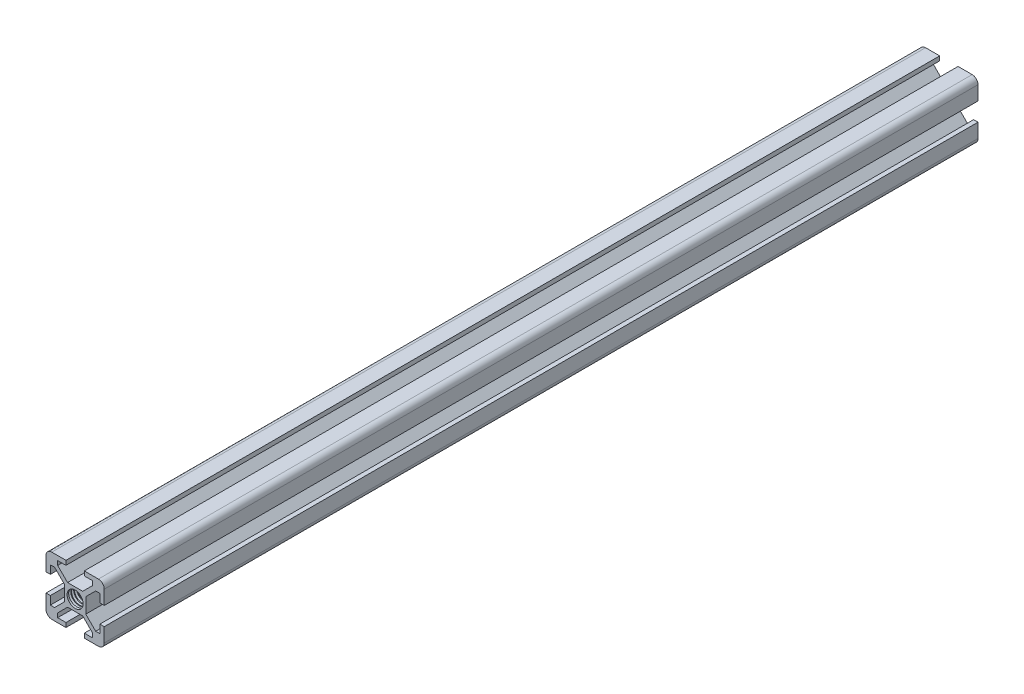
from build123d import *

# Parameters (mm, degrees)
SKETCH1_R           = 2.75
BOSS_EXTRUDE1_DEPTH = 300
CUT_SWEEP2_PITCH    = 1
CUT_SWEEP2_HEIGHT   = 18.5
CUT_SWEEP2_RADIUS   = 2.15


with BuildPart() as part:
    # Sketch1 → Boss-Extrude1 (new body)
    with BuildSketch(Plane.XY):
        with BuildLine():
            Line((-2.599339828, -3.66), (2.599339828, -3.66))
            Line((2.599339828, -3.66), (5.995, -7.055660172))
            Line((5.995, -7.055660172), (5.995, -8.5))
            Line((5.995, -8.5), (3.15, -8.5))
            Line((3.15, -8.5), (3.15, -10))
            Line((3.15, -10), (8, -10))
            ThreePointArc((8, -10), (9.414213562, -9.414213562), (10, -8))
            Line((10, -8), (10, -3.15))
            Line((10, -3.15), (8.5, -3.15))
            Line((8.5, -3.15), (8.5, -5.995))
            Line((8.5, -5.995), (7.055660172, -5.995))
            Line((7.055660172, -5.995), (3.66, -2.599339828))
            Line((3.66, -2.599339828), (3.66, 2.599339828))
            Line((3.66, 2.599339828), (7.055660172, 5.995))
            Line((7.055660172, 5.995), (8.5, 5.995))
            Line((8.5, 5.995), (8.5, 3.15))
            Line((8.5, 3.15), (10, 3.15))
            Line((10, 3.15), (10, 8))
            ThreePointArc((10, 8), (9.414213562, 9.414213562), (8, 10))
            Line((8, 10), (3.15, 10))
            Line((3.15, 10), (3.15, 8.5))
            Line((3.15, 8.5), (5.995, 8.5))
            Line((5.995, 8.5), (5.995, 7.055660172))
            Line((5.995, 7.055660172), (2.599339828, 3.66))
            Line((2.599339828, 3.66), (-2.599339828, 3.66))
            Line((-2.599339828, 3.66), (-5.995, 7.055660172))
            Line((-5.995, 7.055660172), (-5.995, 8.5))
            Line((-5.995, 8.5), (-3.15, 8.5))
            Line((-3.15, 8.5), (-3.15, 10))
            Line((-3.15, 10), (-8, 10))
            ThreePointArc((-8, 10), (-9.414213562, 9.414213562), (-10, 8))
            Line((-10, 8), (-10, 3.15))
            Line((-10, 3.15), (-8.5, 3.15))
            Line((-8.5, 3.15), (-8.5, 5.995))
            Line((-8.5, 5.995), (-7.055660172, 5.995))
            Line((-7.055660172, 5.995), (-3.66, 2.599339828))
            Line((-3.66, 2.599339828), (-3.66, -2.599339828))
            Line((-3.66, -2.599339828), (-7.055660172, -5.995))
            Line((-7.055660172, -5.995), (-8.5, -5.995))
            Line((-8.5, -5.995), (-8.5, -3.15))
            Line((-8.5, -3.15), (-10, -3.15))
            Line((-10, -3.15), (-10, -8))
            ThreePointArc((-10, -8), (-9.414213562, -9.414213562), (-8, -10))
            Line((-8, -10), (-3.15, -10))
            Line((-3.15, -10), (-3.15, -8.5))
            Line((-3.15, -8.5), (-5.995, -8.5))
            Line((-5.995, -8.5), (-5.995, -7.055660172))
            Line((-5.995, -7.055660172), (-2.599339828, -3.66))
        make_face()
        Circle(SKETCH1_R, mode=Mode.SUBTRACT)
    extrude(amount=BOSS_EXTRUDE1_DEPTH)

    # Cut-Sweep2: sweep along a helix
    with BuildLine() as cut_sweep2_path:
        Helix(CUT_SWEEP2_PITCH, CUT_SWEEP2_HEIGHT, CUT_SWEEP2_RADIUS, center=(0, 0, 1), direction=(0, 0, 1))
    # Sketch3 → Cut-Sweep2 (sweep, cut)
    with BuildSketch(Plane(origin=(0, 0, 0), x_dir=(0, 0, -1), z_dir=(1, 0, 0))):
        Polygon((-0.65, 3.389519053), (-1.025, 2.74), (-0.275, 2.74), align=None)
    cut_sweep2 = sweep(path=cut_sweep2_path.line, is_frenet=True, mode=Mode.SUBTRACT)

    # Mirror1: Cut-Sweep2 across plane
    add(cut_sweep2.mirror(Plane(origin=(0, 0, 150), x_dir=(1, 0, 0), z_dir=(0, 0, -1))), mode=Mode.SUBTRACT)


solid = part.part
